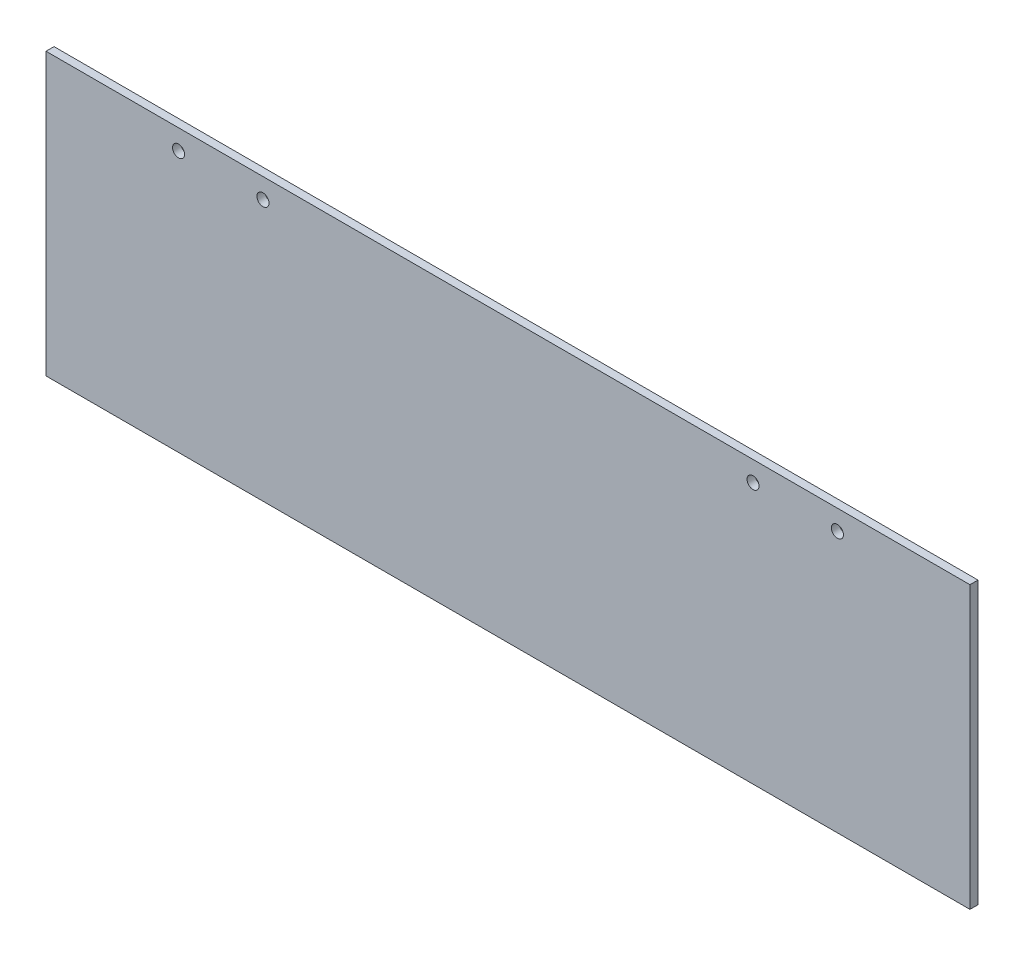
from build123d import *

# Parameters (mm, degrees)
ESQUISSE1_W        = 230
ESQUISSE1_H        = 70
ESQUISSE1_R        = 1.5
BOSS_EXTRU_1_DEPTH = 2


with BuildPart() as part:
    # Esquisse1 → Boss.-Extru.1 (new body)
    with BuildSketch(Plane.XY):
        Rectangle(ESQUISSE1_W, ESQUISSE1_H)
        with Locations((-82, 30)):
            Circle(ESQUISSE1_R, mode=Mode.SUBTRACT)
        with Locations((-61, 30)):
            Circle(ESQUISSE1_R, mode=Mode.SUBTRACT)
        with Locations((61, 30)):
            Circle(ESQUISSE1_R, mode=Mode.SUBTRACT)
        with Locations((82, 30)):
            Circle(ESQUISSE1_R, mode=Mode.SUBTRACT)
    extrude(amount=BOSS_EXTRU_1_DEPTH)


solid = part.part
